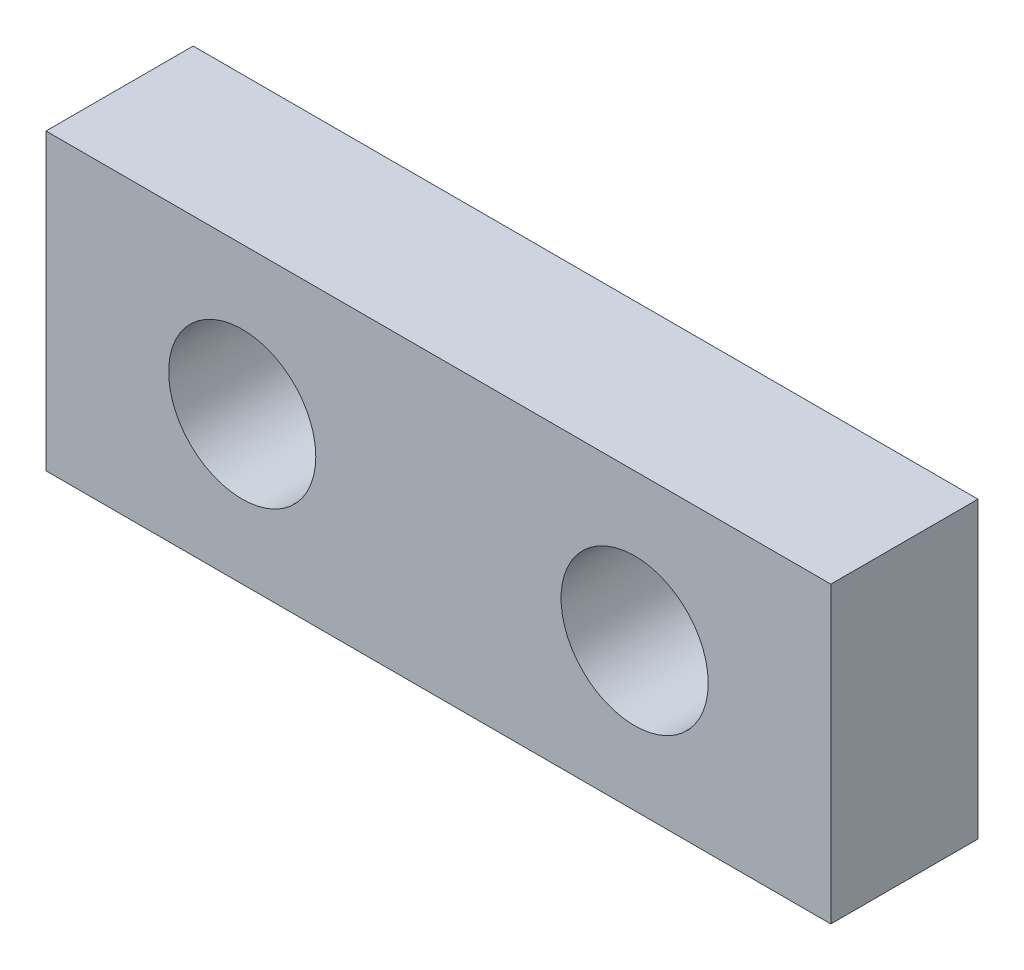
from build123d import *

# Parameters (mm, degrees)
SKETCH_1_W          = 16
SKETCH_1_H          = 6
EXTRUDE_1_DEPTH     = 3
SKETCH_2_R          = 1.5
CUT_EXTRUDE_1_DEPTH = 3


with BuildPart() as part:
    # ｽｹｯﾁ1 → ﾎﾞｽ - 押し出し1 (new body)
    with BuildSketch(Plane.XY):
        Rectangle(SKETCH_1_W, SKETCH_1_H)
    extrude(amount=EXTRUDE_1_DEPTH)

    # ｽｹｯﾁ2 → ｶｯﾄ - 押し出し1 (cut)
    with BuildSketch(Plane.XY.offset(3)):
        with Locations((-4, 0)):
            Circle(SKETCH_2_R)
        with Locations((4, 0)):
            Circle(SKETCH_2_R)
    extrude(amount=-CUT_EXTRUDE_1_DEPTH, mode=Mode.SUBTRACT)


solid = part.part
